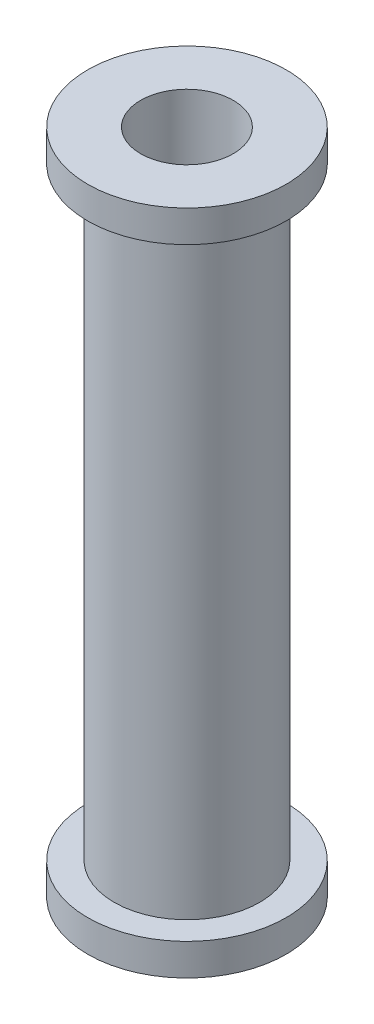
from build123d import *

# Parameters (mm, degrees)
SKETCH1_R           = 9.525
SKETCH1_R_2         = 4.445
BOSS_EXTRUDE1_DEPTH = 3.048
SKETCH2_R           = 6.985
SKETCH2_R_2         = 4.445
BOSS_EXTRUDE2_DEPTH = 57.912
SKETCH3_R           = 9.525
SKETCH3_R_2         = 6.985
SKETCH3_R_3         = 4.445
BOSS_EXTRUDE3_DEPTH = 3.048


with BuildPart() as part:
    # Sketch1 → Boss-Extrude1 (new body)
    with BuildSketch(Plane(origin=(0, 0, 0), x_dir=(1, 0, 0), z_dir=(0, 1, 0))):
        with Locations(Location((0, 0, 0), (0, 0, 270))):  # turned: the seam where the file's is
            Circle(SKETCH1_R)
        with Locations(Location((0, 0, 0), (0, 0, 270))):  # turned: the seam where the file's is
            Circle(SKETCH1_R_2, mode=Mode.SUBTRACT)
    extrude(amount=BOSS_EXTRUDE1_DEPTH)

    # Sketch2 → Boss-Extrude2 (add)
    with BuildSketch(Plane(origin=(0, 3.048, 0), x_dir=(1, 0, 0), z_dir=(0, 1, 0))):
        with Locations(Location((0, 0, 0), (0, 0, 270))):  # turned: the seam where the file's is
            Circle(SKETCH2_R)
        with Locations(Location((0, 0, 0), (0, 0, 270))):  # turned: the seam where the file's is
            Circle(SKETCH2_R_2, mode=Mode.SUBTRACT)
    extrude(amount=BOSS_EXTRUDE2_DEPTH)

    # Sketch3 → Boss-Extrude3 (add)
    with BuildSketch(Plane(origin=(0, 60.96, 0), x_dir=(1, 0, 0), z_dir=(0, 1, 0))):
        with Locations(Location((0, 0, 0), (0, 0, 270))):  # turned: the seam where the file's is
            Circle(SKETCH3_R)
        with Locations(Location((0, 0, 0), (0, 0, 270))):  # turned: the seam where the file's is
            Circle(SKETCH3_R_2, mode=Mode.SUBTRACT)
        with Locations(Location((0, 0, 0), (0, 0, 270))):  # turned: the seam where the file's is
            Circle(SKETCH3_R_2)
        with Locations(Location((0, 0, 0), (0, 0, 270))):  # turned: the seam where the file's is
            Circle(SKETCH3_R_3, mode=Mode.SUBTRACT)
    extrude(amount=BOSS_EXTRUDE3_DEPTH)


solid = part.part
